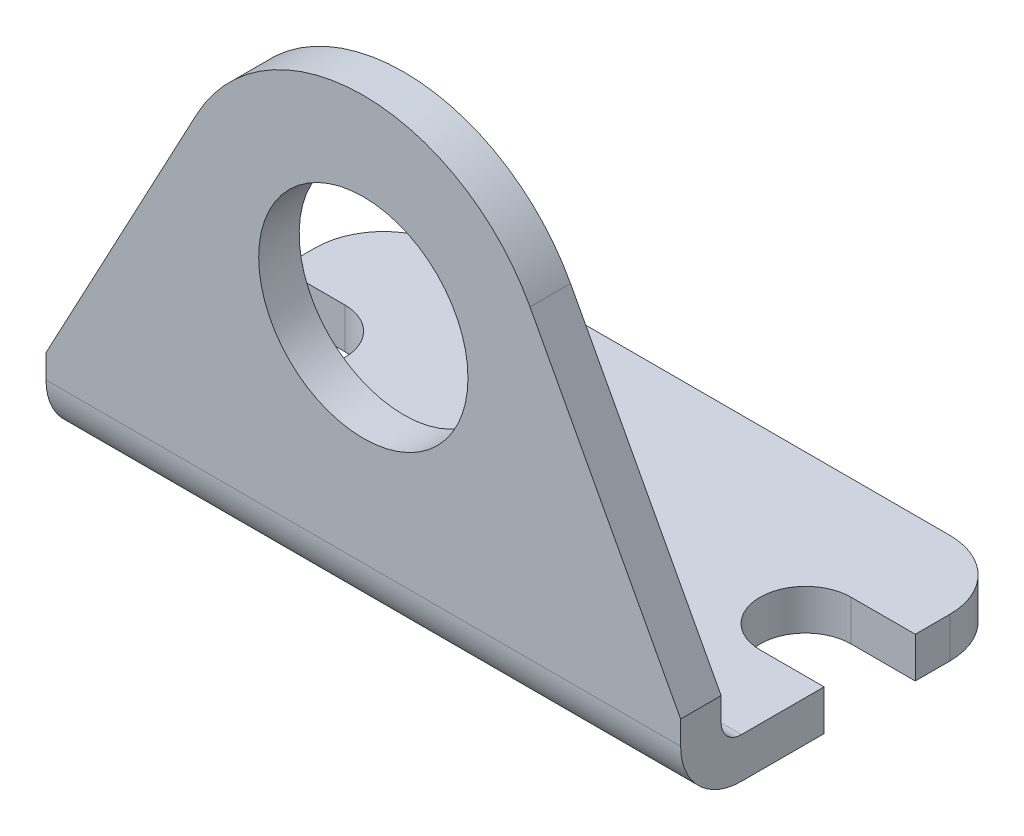
from build123d import *

# Parameters (mm, degrees)
SKETCH3_R                = 7.874
BOSS_EXTRUDE1_DEPTH      = 14.224
BOSS_EXTRUDE1_DEPTH_BACK = 11.176
CUT_EXTRUDE1_DEPTH       = 36.052
CUT_EXTRUDE2_DEPTH       = 48.752
FILLET1_R                = 5.1435


with BuildPart() as part:
    # Sketch3 → Boss-Extrude1 (new body, two sides)
    with BuildSketch(Plane.XY) as boss_extrude1_sk:
        with BuildLine():
            Line((-23.876, 0), (23.876, 0))
            Line((23.876, 0), (23.876, 6.35))
            Line((23.876, 6.35), (12.542250985, 27.537256011))
            ThreePointArc((12.542250985, 27.537256011), (0, 35.052), (-12.542250985, 27.537256011))
            Line((-12.542250985, 27.537256011), (-23.876, 6.35))
            Line((-23.876, 6.35), (-23.876, 0))
        make_face()
        with Locations((0, 20.574)):
            Circle(SKETCH3_R, mode=Mode.SUBTRACT)
    extrude(amount=BOSS_EXTRUDE1_DEPTH)
    extrude(boss_extrude1_sk.sketch, amount=-BOSS_EXTRUDE1_DEPTH_BACK)

    # Sketch4 → Cut-Extrude1 (cut, through all)
    with BuildSketch(Plane(origin=(0, 0, 0), x_dir=(1, 0, 0), z_dir=(0, 1, 0))):
        with BuildLine():
            Line((-23.876, 3.429), (-23.876, -3.429))
            Line((-23.876, -3.429), (-19.05, -3.429))
            ThreePointArc((-19.05, -3.429), (-15.621, 0), (-19.05, 3.429))
            Line((-19.05, 3.429), (-23.876, 3.429))
        make_face()
        with BuildLine():
            Line((19.05, 3.429), (23.876, 3.429))
            Line((23.876, 3.429), (23.876, -3.429))
            Line((23.876, -3.429), (19.05, -3.429))
            ThreePointArc((19.05, -3.429), (15.621, 0), (19.05, 3.429))
        make_face()
    extrude(amount=CUT_EXTRUDE1_DEPTH, mode=Mode.SUBTRACT)

    # Sketch5 → Cut-Extrude2 (cut, through all)
    with BuildSketch(Plane.ZY.offset(23.876)):
        with BuildLine():
            Line((-11.176, 35.052), (11.176, 35.052))
            Line((11.176, 35.052), (11.176, 4.572))
            ThreePointArc((11.176, 4.572), (10.729630735, 3.494369265), (9.652, 3.048))
            Line((9.652, 3.048), (-11.176, 3.048))
            Line((-11.176, 3.048), (-11.176, 35.052))
        make_face()
        with BuildLine():
            Line((9.652, 0), (14.224, 0))
            Line((14.224, 0), (14.224, 4.572))
            ThreePointArc((14.224, 4.572), (12.884892204, 1.339107796), (9.652, 0))
        make_face()
    extrude(amount=-CUT_EXTRUDE2_DEPTH, mode=Mode.SUBTRACT)

    # Fillet1
    fillet1_edges = [part.edges().sort_by_distance(p)[0] for p in [
        (23.876, 1.524, -11.176),
        (-23.876, 1.524, -11.176),
    ]]
    fillet(fillet1_edges, radius=FILLET1_R)


solid = part.part
